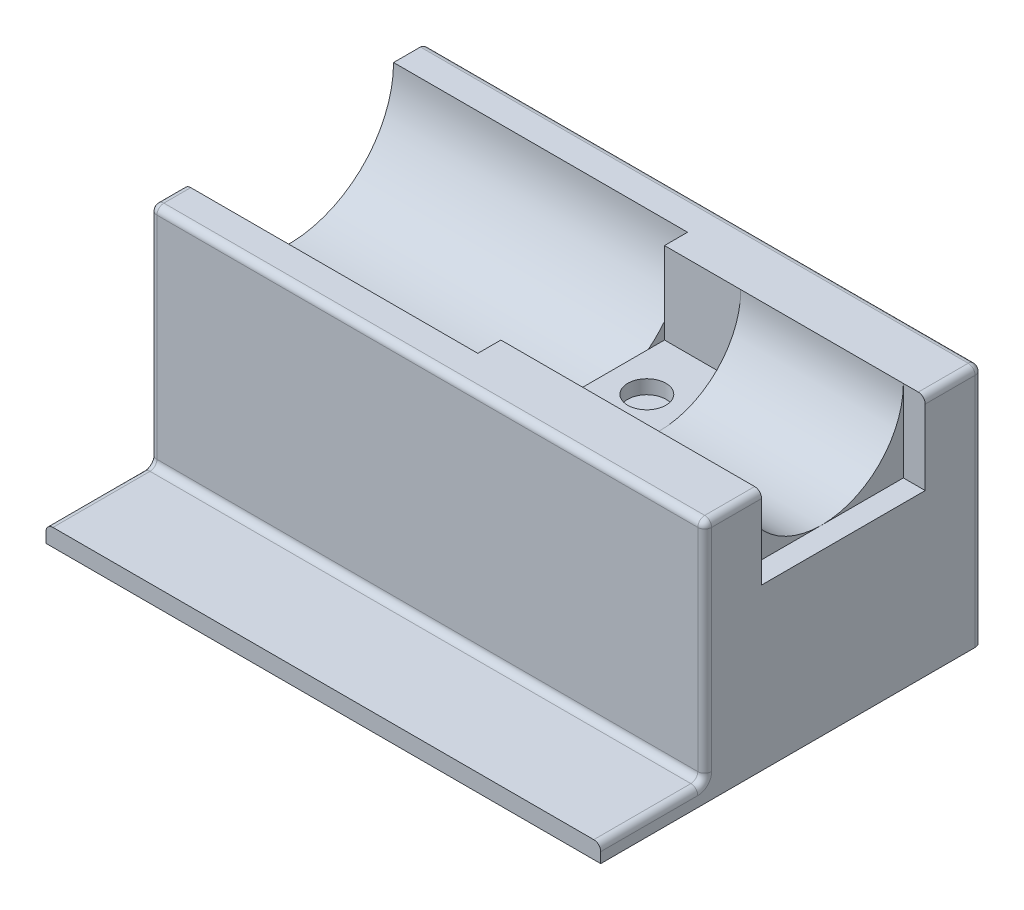
from build123d import *

# Parameters (mm, degrees)
BOSS_EXTRUDE1_DEPTH = 88.89999999999999
SKETCH2_R           = 29.97200000000001
CUT_EXTRUDE1_DEPTH  = 203.2
CUT_EXTRUDE2_DEPTH  = 8.001
SKETCH4_W           = 59.943999999999946
SKETCH4_H           = 29.972
CUT_EXTRUDE3_DEPTH  = 27.94
SKETCH5_R           = 38.417500000000004
CUT_EXTRUDE4_DEPTH  = 107.696
CUT_EXTRUDE5_DEPTH  = 5.08
SKETCH7_W           = 203.19999999999996
SKETCH7_H           = 6.349999999999999
BOSS_EXTRUDE2_DEPTH = 38.1
FILLET1_R           = 2.54


with BuildPart() as part:
    # Sketch1 → Boss-Extrude1 (new body)
    with BuildSketch(Plane(origin=(0, 0, 0), x_dir=(1, 0, 0), z_dir=(0, 1, 0))):
        Polygon((0, 0), (203.2, 0), (203.2, -101.6), (1.244e-14, -101.6), align=None)
    extrude(amount=BOSS_EXTRUDE1_DEPTH)

    # Sketch2 → Cut-Extrude1 (cut)
    with BuildSketch(Plane(origin=(203.2, 0, 0), x_dir=(-2.2e-16, 0, -1), z_dir=(1, 0, -2.2e-16))):
        with Locations((-50.8, 88.89999999999999)):
            Circle(SKETCH2_R)
    extrude(amount=-CUT_EXTRUDE1_DEPTH, mode=Mode.SUBTRACT)

    # Sketch3 → Cut-Extrude2 (cut)
    with BuildSketch(Plane(origin=(203.2, 0, 0), x_dir=(-2.2e-16, 0, -1), z_dir=(1, 0, -2.2e-16))):
        Polygon((-20.82800000000002, 118.87199999999997), (-80.77199999999996, 118.87199999999996), (-80.77199999999996, 58.928000000000004), (-20.828000000000007, 58.928000000000004), align=None)
    extrude(amount=-CUT_EXTRUDE2_DEPTH, mode=Mode.SUBTRACT)

    # Sketch4 → Cut-Extrude3 (cut)
    with BuildSketch(Plane(origin=(135.636, 0, 0), x_dir=(-2.2e-16, 0, -1), z_dir=(1, 0, -2.2e-16))):
        with Locations((-50.800000000000004, 73.914)):
            Rectangle(SKETCH4_W, SKETCH4_H)
    extrude(amount=-CUT_EXTRUDE3_DEPTH, mode=Mode.SUBTRACT)

    # Sketch5 → Cut-Extrude4 (cut)
    with BuildSketch(Plane.ZY):
        with Locations((50.8, 88.89999999999999)):
            Circle(SKETCH5_R)
    extrude(amount=-CUT_EXTRUDE4_DEPTH, mode=Mode.SUBTRACT)

    # Sketch6 → Cut-Extrude5 (cut)
    with BuildSketch(Plane(origin=(0, 58.928000000000004, 0), x_dir=(1, 0, 0), z_dir=(0, 1, 0))):
        with BuildLine():
            ThreePointArc((121.66599999999983, -34.29000000000002), (114.68100000000004, -41.275000000000006), (121.66599999999983, -48.25999999999999))
            Line((121.66600000000003, -48.25999999999999), (121.66600000000003, -34.29000000000002))
        make_face()
        with BuildLine():
            Line((121.66600000000003, -34.29000000000002), (121.66600000000003, -48.25999999999999))
            ThreePointArc((121.66599999999983, -48.25999999999999), (126.60514086658797, -46.214140866588096), (128.651, -41.275000000000006))
            ThreePointArc((128.651, -41.275000000000006), (126.60514086658797, -36.335859133411915), (121.66599999999983, -34.29000000000002))
        make_face()
    extrude(amount=-CUT_EXTRUDE5_DEPTH, mode=Mode.SUBTRACT)

    # Sketch7 → Boss-Extrude2 (add)
    with BuildSketch(Plane.XY.offset(101.6)):
        with Locations((101.59999999999998, 3.1749999999999994)):
            Rectangle(SKETCH7_W, SKETCH7_H)
    extrude(amount=BOSS_EXTRUDE2_DEPTH)

    # Fillet1
    fillet1_edges = [part.edges().sort_by_distance(p)[0] for p in [
        (101.6, 6.35, 101.6),
        (0, 6.35, 120.64999999999999),
        (203.2, 6.35, 120.64999999999999),
        (0, 44.449999999999996, 0),
        (1.168e-14, 88.89999999999999, 95.40875),
        (1.244e-14, 47.625, 101.6),
        (101.6, 88.89999999999999, 0),
        (203.2, 44.449999999999996, 0),
        (203.2, 88.89999999999999, 10.413999999999994),
        (203.2, 88.89999999999999, 91.186),
        (101.6, 88.89999999999999, 101.6),
        (203.2, 47.625, 101.6),
    ]]
    fillet(fillet1_edges, radius=FILLET1_R)


solid = part.part
